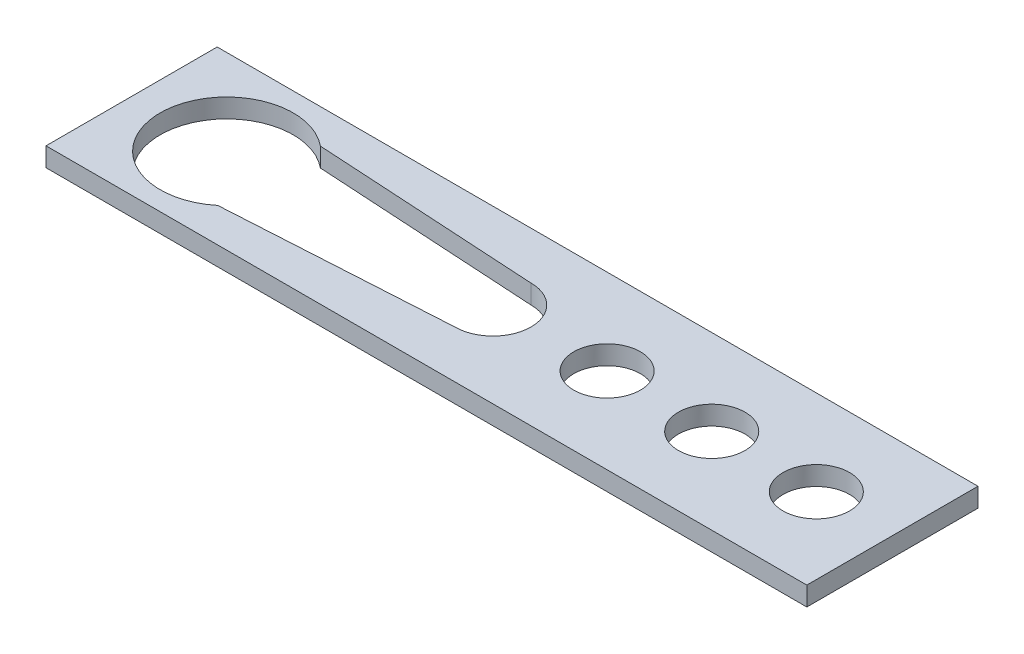
from build123d import *

# Parameters (mm, degrees)
SKETCH2_W           = 40
SKETCH2_H           = 9
BOSS_EXTRUDE1_DEPTH = 1
CUT_EXTRUDE1_DEPTH  = 3
SKETCH4_R           = 1.75
CUT_EXTRUDE2_DEPTH  = 3
LPATTERN1_COUNT     = 3
LPATTERN1_PITCH     = 5.5


with BuildPart() as part:
    # Sketch2 → Boss-Extrude1 (new body)
    with BuildSketch(Plane(origin=(0, 0, 0), x_dir=(1, 0, 0), z_dir=(0, 1, 0))):
        Rectangle(SKETCH2_W, SKETCH2_H)
    extrude(amount=BOSS_EXTRUDE1_DEPTH)

    # Sketch3 → Cut-Extrude1 (cut)
    with BuildSketch(Plane(origin=(0, 1, 0), x_dir=(1, 0, 0), z_dir=(0, 1, 0))):
        with BuildLine():
            Line((-12.772894255, -2.7), (-1, -2))
            ThreePointArc((-1, -2), (1, 0), (-1, 2))
            Line((-1, 2), (-12.772894255, 2.7))
            ThreePointArc((-12.772894255, 2.7), (-18.5, 0), (-12.772894255, -2.7))
        make_face()
    extrude(amount=-CUT_EXTRUDE1_DEPTH, mode=Mode.SUBTRACT)

    # Sketch4 → Cut-Extrude2 (cut)
    with BuildSketch(Plane(origin=(0, 1, 0), x_dir=(1, 0, 0), z_dir=(0, 1, 0))):
        with Locations((5, 0)):
            Circle(SKETCH4_R)
    cut_extrude2 = extrude(amount=-CUT_EXTRUDE2_DEPTH, mode=Mode.SUBTRACT)

    # LPattern1: Cut-Extrude2 ×3
    with Locations(*[(i * LPATTERN1_PITCH, 0, 0) for i in range(1, LPATTERN1_COUNT)]):
        add(cut_extrude2, mode=Mode.SUBTRACT)


solid = part.part
